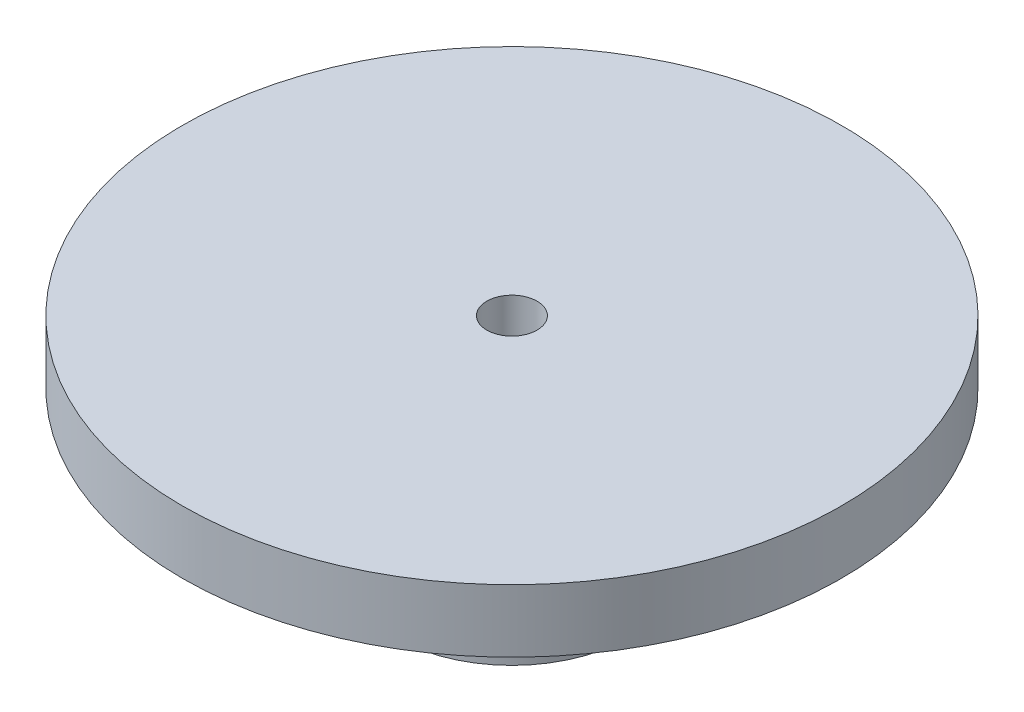
from build123d import *

# Parameters (mm, degrees)
CROQUIS1_R              = 3.75
CROQUIS1_R_2            = 3
SALIENTE_EXTRUIR1_DEPTH = 5
CROQUIS2_R              = 10.5
CROQUIS2_R_2            = 0.8
SALIENTE_EXTRUIR2_DEPTH = 2


with BuildPart() as part:
    # Croquis1 → Saliente-Extruir1 (new body)
    with BuildSketch(Plane(origin=(0, 0, 0), x_dir=(1, 0, 0), z_dir=(0, 1, 0))):
        Circle(CROQUIS1_R)
        Circle(CROQUIS1_R_2, mode=Mode.SUBTRACT)
    extrude(amount=SALIENTE_EXTRUIR1_DEPTH)

    # Croquis2 → Saliente-Extruir2 (add)
    with BuildSketch(Plane(origin=(0, 5, 0), x_dir=(1, 0, 0), z_dir=(0, 1, 0))):
        Circle(CROQUIS2_R)
        Circle(CROQUIS2_R_2, mode=Mode.SUBTRACT)
    extrude(amount=SALIENTE_EXTRUIR2_DEPTH)


solid = part.part
